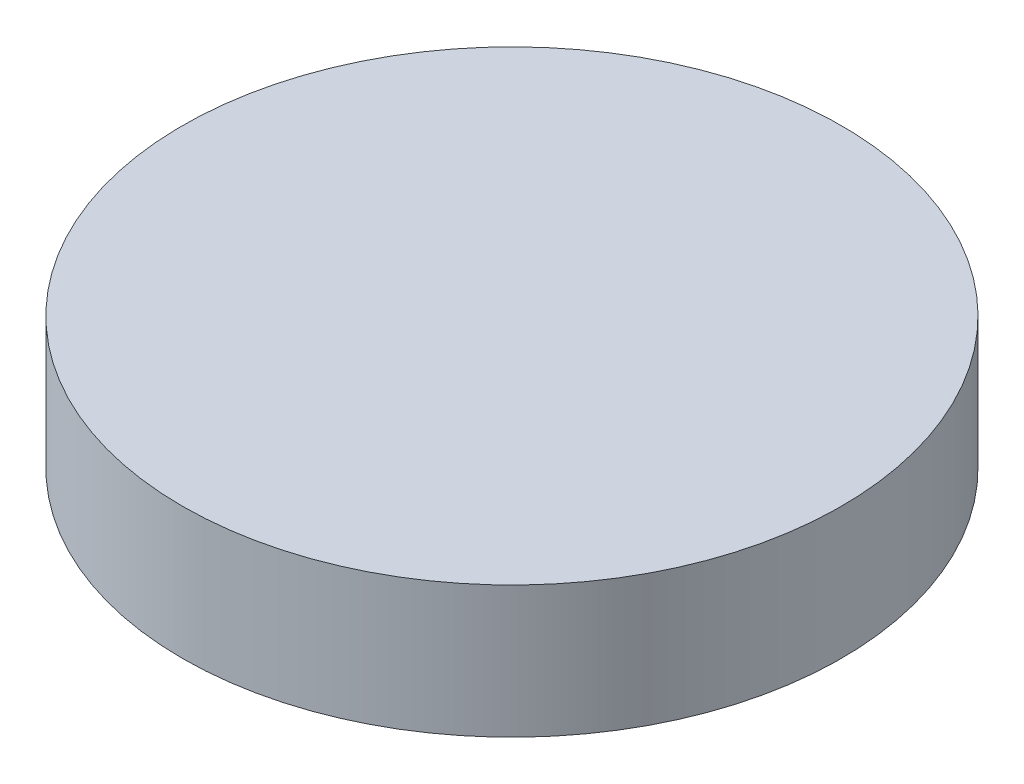
from build123d import *

# Parameters (mm, degrees)
SKETCH1_R           = 5
BOSS_EXTRUDE1_DEPTH = 2


with BuildPart() as part:
    # Sketch1 → Boss-Extrude1 (new body)
    with BuildSketch(Plane(origin=(0, 0, 0), x_dir=(1, 0, 0), z_dir=(0, 1, 0))):
        Circle(SKETCH1_R)
    extrude(amount=BOSS_EXTRUDE1_DEPTH)


solid = part.part
